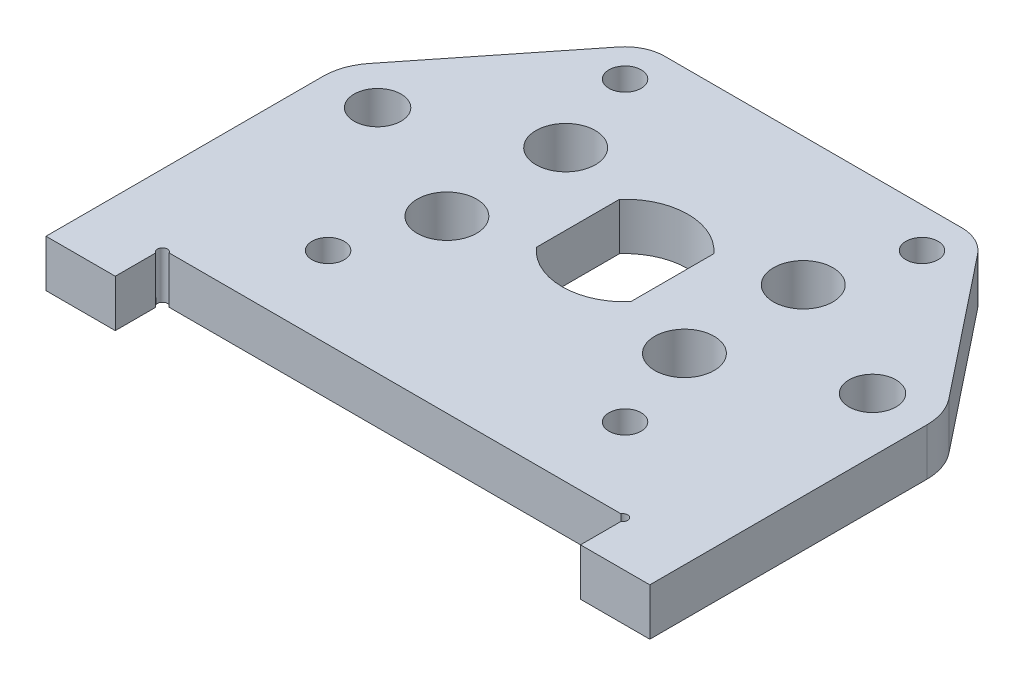
from build123d import *

# Parameters (mm, degrees)
SKETCH1_R           = 1.625
SKETCH1_R_2         = 2.375
SKETCH1_R_3         = 3
BOSS_EXTRUDE1_DEPTH = 4.7625
SKETCH2_R           = 0.5
CUT_EXTRUDE1_DEPTH  = 5.7625


with BuildPart() as part:
    # Sketch1 → Boss-Extrude1 (new body)
    with BuildSketch(Plane(origin=(0, 0, 0), x_dir=(1, 0, 0), z_dir=(0, 1, 0))):
        with BuildLine():
            Line((-4.7625, -4.200130206), (-4.7625, 4.200130206))
            ThreePointArc((-4.7625, 4.200130206), (-2.612630206, 5.787630206), (0, 6.35))
            Line((0, 6.35), (0, 19))
            Line((0, 19), (-15, 19))
            ThreePointArc((-15, 19), (-16.738947924, 18.602229881), (-18.132045087, 17.488030058))
            Line((-18.132045087, 17.488030058), (-29.306561995, 3.42104133))
            ThreePointArc((-29.306561995, 3.42104133), (-30.193076688, 1.811616547), (-30.5, 0))
            Line((-30.5, 0), (-30.5, -28))
            Line((-30.5, -28), (-23.5, -28))
            Line((-23.5, -28), (-23.5, -23.2375))
            Line((-23.5, -23.2375), (0, -23.2375))
            Line((0, -23.2375), (0, -6.35))
            ThreePointArc((0, -6.35), (-2.612630206, -5.787630206), (-4.7625, -4.200130206))
        make_face()
        with Locations((-15, 15)):
            Circle(SKETCH1_R, mode=Mode.SUBTRACT)
        with Locations((-15, -15)):
            Circle(SKETCH1_R, mode=Mode.SUBTRACT)
        with Locations((-25, 0)):
            Circle(SKETCH1_R_2, mode=Mode.SUBTRACT)
        with Locations((-12, -6)):
            Circle(SKETCH1_R_3, mode=Mode.SUBTRACT)
        with Locations((-12, 6)):
            Circle(SKETCH1_R_3, mode=Mode.SUBTRACT)
    boss_extrude1 = extrude(amount=BOSS_EXTRUDE1_DEPTH)

    # Mirror1: Boss-Extrude1 across plane
    add(boss_extrude1.mirror(Plane(origin=(0, 4.7625, 6.35), x_dir=(0, 0, 1), z_dir=(-1, 0, 0))))

    # Sketch2 → Cut-Extrude1 (cut, through all)
    with BuildSketch(Plane(origin=(0, 4.7625, 0), x_dir=(1, 0, 0), z_dir=(0, 1, 0))):
        with Locations((-23.25, -23.4875)):
            Circle(SKETCH2_R)
        with Locations((23.25, -23.4875)):
            Circle(SKETCH2_R)
    extrude(amount=-CUT_EXTRUDE1_DEPTH, mode=Mode.SUBTRACT)


solid = part.part
